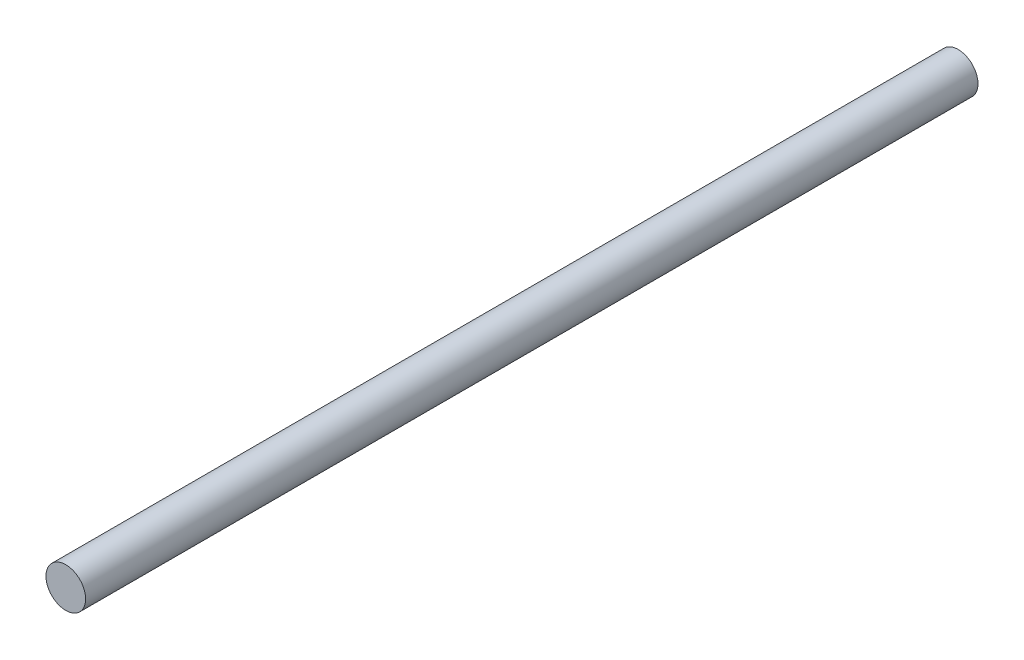
from build123d import *

# Parameters (mm, degrees)
SKETCH2_R           = 4
BOSS_EXTRUDE1_DEPTH = 180


with BuildPart() as part:
    # Sketch2 → Boss-Extrude1 (new body)
    with BuildSketch(Plane.XY):
        Circle(SKETCH2_R)
    extrude(amount=BOSS_EXTRUDE1_DEPTH)


solid = part.part
